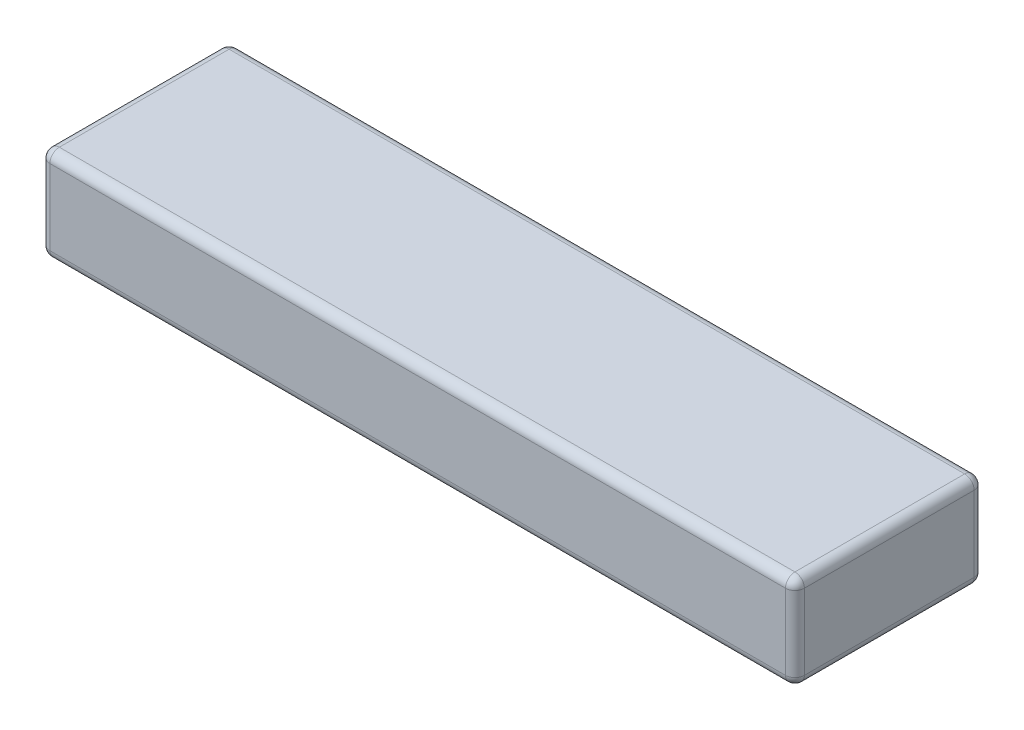
from build123d import *

# Parameters (mm, degrees)
SKETCH1_W           = 40
SKETCH1_H           = 10
BOSS_EXTRUDE1_DEPTH = 5
FILLET1_R           = 0.5


with BuildPart() as part:
    # Sketch1 → Boss-Extrude1 (new body)
    with BuildSketch(Plane(origin=(0, 0, 0), x_dir=(1, 0, 0), z_dir=(0, 1, 0))):
        Rectangle(SKETCH1_W, SKETCH1_H)
    extrude(amount=BOSS_EXTRUDE1_DEPTH)

    # Fillet1
    fillet1_edges = [part.edges().sort_by_distance(p)[0] for p in [
        (-20, 5, 0),
        (0, 5, 5),
        (20, 5, 0),
        (0, 0, 5),
        (-20, 0, 0),
        (0, 0, -5),
        (20, 0, 0),
        (0, 5, -5),
        (20, 2.5, 5),
        (-20, 2.5, 5),
        (-20, 2.5, -5),
        (20, 2.5, -5),
    ]]
    fillet(fillet1_edges, radius=FILLET1_R)


solid = part.part
